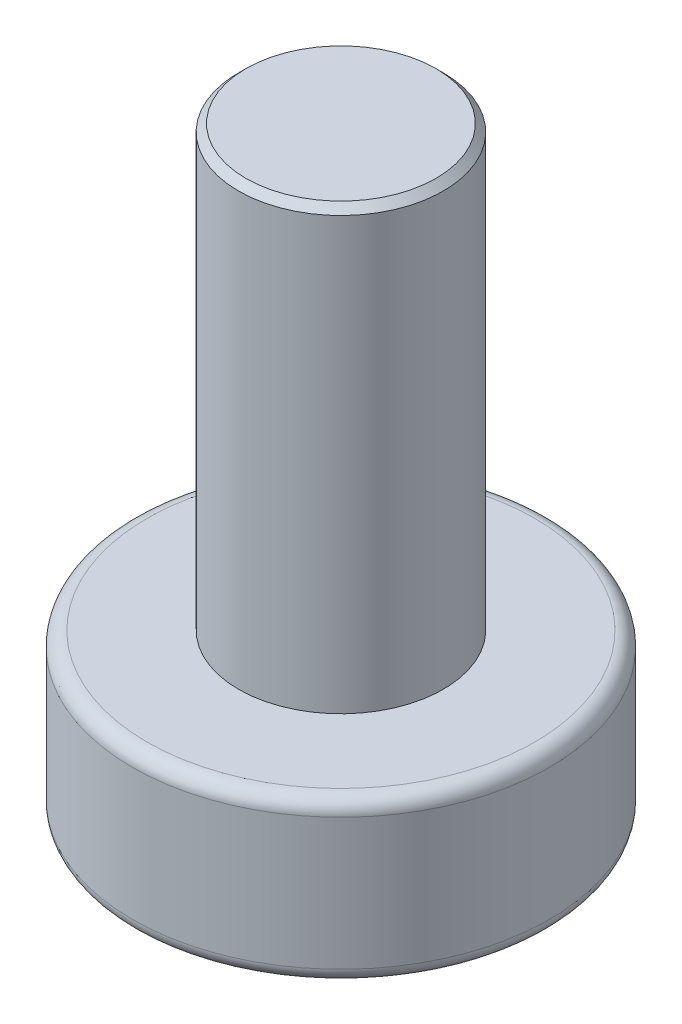
from build123d import *

# Parameters (mm, degrees)
SKETCH_1_R          = 2.85
EXTRUDE_1_DEPTH     = 2.2
SKETCH_2_R          = 1.4
EXTRUDE_2_DEPTH     = 6
CHAMFER_1_SIZE      = 0.1
FILLET_1_R          = 0.2
CUT_EXTRUDE_1_DEPTH = 1.5


with BuildPart() as part:
    # Эскиз1 → Бобышка-Вытянуть1 (new body)
    with BuildSketch(Plane(origin=(0, 0, 0), x_dir=(1, 0, 0), z_dir=(0, 1, 0))):
        Circle(SKETCH_1_R)
    extrude(amount=EXTRUDE_1_DEPTH)

    # Эскиз2 → Бобышка-Вытянуть2 (add)
    with BuildSketch(Plane(origin=(0, 2.2, 0), x_dir=(1, 0, 0), z_dir=(0, 1, 0))):
        Circle(SKETCH_2_R)
    extrude(amount=EXTRUDE_2_DEPTH)

    # Фаска1
    chamfer_1_edges = [part.edges().sort_by_distance(p)[0] for p in [
        (-1.4, 8.2, 0),
    ]]
    chamfer(chamfer_1_edges, length=CHAMFER_1_SIZE)

    # Скругление1
    fillet_1_edges = [part.edges().sort_by_distance(p)[0] for p in [
        (-2.85, 0, 0),
        (-2.85, 2.2, 0),
    ]]
    fillet(fillet_1_edges, radius=FILLET_1_R)

    # Эскиз3 → Вырез-Вытянуть1 (cut)
    with BuildSketch(Plane.XZ):
        Polygon((-0.5, 0.5), (-0.5, 2), (0.5, 2), (0.5, 0.5), (2, 0.5), (2, -0.5), (0.5, -0.5), (0.5, -2), (-0.5, -2), (-0.5, -0.5), (-2, -0.5), (-2, 0.5), align=None)
    extrude(amount=-CUT_EXTRUDE_1_DEPTH, mode=Mode.SUBTRACT)


solid = part.part
